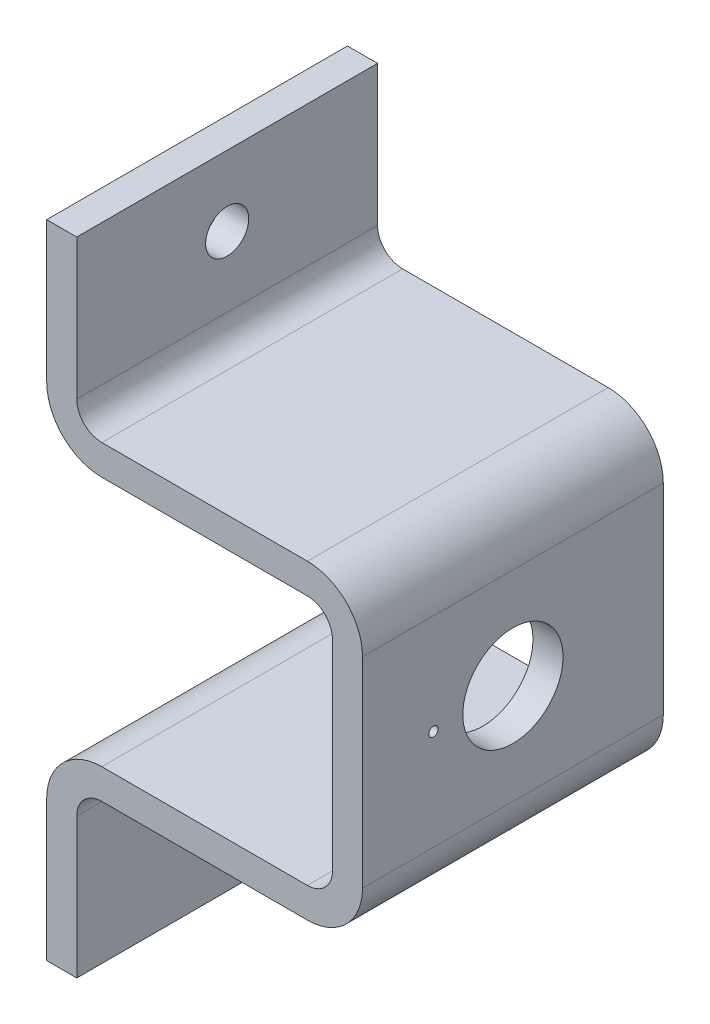
from build123d import *

# Parameters (mm, degrees)
BOSS_EXTRUDE1_DEPTH       = 30
M4_CLEARANCE_HOLE1_D      = 4.3
M4_CLEARANCE_HOLE1_DEPTH  = 7
M10_CLEARANCE_HOLE1_D     = 10
M10_CLEARANCE_HOLE1_DEPTH = 7
SKETCH6_R                 = 0.475
CUT_EXTRUDE1_DEPTH        = 10


with BuildPart() as part:
    # Sketch1 → Boss-Extrude1 (new body)
    with BuildSketch(Plane.XY):
        with BuildLine():
            Line((0, 0), (0, 14))
            ThreePointArc((0, 14), (1.610912703, 17.889087297), (5.5, 19.5))
            Line((5.5, 19.5), (26, 19.5))
            ThreePointArc((26, 19.5), (27.767766953, 20.232233047), (28.5, 22))
            Line((28.5, 22), (28.5, 42))
            ThreePointArc((28.5, 42), (27.767766953, 43.767766953), (26, 44.5))
            Line((26, 44.5), (5.5, 44.5))
            ThreePointArc((5.5, 44.5), (1.610912703, 46.110912703), (0, 50))
            Line((0, 50), (0, 64))
            Line((0, 64), (3, 64))
            Line((3, 64), (3, 50))
            ThreePointArc((3, 50), (3.732233047, 48.232233047), (5.5, 47.5))
            Line((5.5, 47.5), (26, 47.5))
            ThreePointArc((26, 47.5), (29.889087297, 45.889087297), (31.5, 42))
            Line((31.5, 42), (31.5, 22))
            ThreePointArc((31.5, 22), (29.889087297, 18.110912703), (26, 16.5))
            Line((26, 16.5), (5.5, 16.5))
            ThreePointArc((5.5, 16.5), (3.732233047, 15.767766953), (3, 14))
            Line((3, 14), (3, 0))
            Line((3, 0), (0, 0))
        make_face()
    extrude(amount=BOSS_EXTRUDE1_DEPTH)

    # M4 Clearance Hole1
    with Locations(Plane(origin=(3, 0, 0), x_dir=(0, 0, -1), z_dir=(1, 0, 0))):
        with Locations((-15, 57), (-15, 7)):
            Hole(M4_CLEARANCE_HOLE1_D / 2, depth=M4_CLEARANCE_HOLE1_DEPTH)

    # M10 Clearance Hole1
    with Locations(Plane(origin=(31.5, 0, 0), x_dir=(0, 0, -1), z_dir=(1, 0, 0))):
        with Locations((-15, 32)):
            Hole(M10_CLEARANCE_HOLE1_D / 2, depth=M10_CLEARANCE_HOLE1_DEPTH)

    # Sketch6 → Cut-Extrude1 (cut)
    with BuildSketch(Plane(origin=(31.5, 0, 0), x_dir=(0, 0, -1), z_dir=(1, 0, 0))):
        with Locations((-22.92, 32)):
            Circle(SKETCH6_R)
    extrude(amount=-CUT_EXTRUDE1_DEPTH, mode=Mode.SUBTRACT)


solid = part.part
